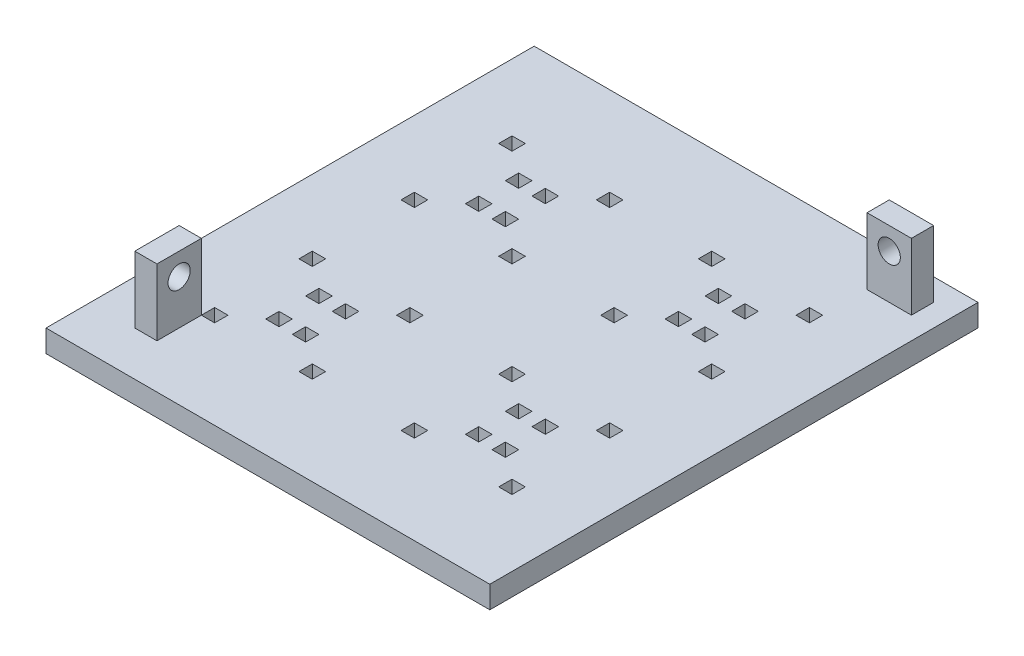
from build123d import *

# Parameters (mm, degrees)
SKETCH1_W           = 100
SKETCH1_H           = 110
SKETCH1_W_2         = 3
SKETCH1_H_2         = 3
BOSS_EXTRUDE1_DEPTH = 5
SKETCH2_W           = 10
SKETCH2_H           = 5
SKETCH2_W_2         = 5
SKETCH2_H_2         = 10
BOSS_EXTRUDE2_DEPTH = 15
SKETCH3_R           = 2.5
CUT_EXTRUDE1_DEPTH  = 15
SKETCH5_R           = 2.5
CUT_EXTRUDE2_DEPTH  = 15


with BuildPart() as part:
    # Sketch1 → Boss-Extrude1 (new body)
    with BuildSketch(Plane(origin=(0, 0, 0), x_dir=(1, 0, 0), z_dir=(0, 1, 0))):
        with Locations((-50, 55)):
            Rectangle(SKETCH1_W, SKETCH1_H)
        with Locations((-38.5, 43.5)):
            Rectangle(SKETCH1_W_2, SKETCH1_H_2, mode=Mode.SUBTRACT)
        with Locations((-16.5, 43.5)):
            Rectangle(SKETCH1_W_2, SKETCH1_H_2, mode=Mode.SUBTRACT)
        with Locations((-38.5, 21.5)):
            Rectangle(SKETCH1_W_2, SKETCH1_H_2, mode=Mode.SUBTRACT)
        with Locations((-16.5, 21.5)):
            Rectangle(SKETCH1_W_2, SKETCH1_H_2, mode=Mode.SUBTRACT)
        with Locations((-30.5, 37)):
            Rectangle(SKETCH1_W_2, SKETCH1_H_2, mode=Mode.SUBTRACT)
        with Locations((-30.5, 28)):
            Rectangle(SKETCH1_W_2, SKETCH1_H_2, mode=Mode.SUBTRACT)
        with Locations((-24.5, 37)):
            Rectangle(SKETCH1_W_2, SKETCH1_H_2, mode=Mode.SUBTRACT)
        with Locations((-24.5, 28)):
            Rectangle(SKETCH1_W_2, SKETCH1_H_2, mode=Mode.SUBTRACT)
        with Locations((-75.5, 28)):
            Rectangle(SKETCH1_W_2, SKETCH1_H_2, mode=Mode.SUBTRACT)
        with Locations((-75.5, 37)):
            Rectangle(SKETCH1_W_2, SKETCH1_H_2, mode=Mode.SUBTRACT)
        with Locations((-69.5, 28)):
            Rectangle(SKETCH1_W_2, SKETCH1_H_2, mode=Mode.SUBTRACT)
        with Locations((-69.5, 37)):
            Rectangle(SKETCH1_W_2, SKETCH1_H_2, mode=Mode.SUBTRACT)
        with Locations((-83.5, 21.5)):
            Rectangle(SKETCH1_W_2, SKETCH1_H_2, mode=Mode.SUBTRACT)
        with Locations((-61.5, 21.5)):
            Rectangle(SKETCH1_W_2, SKETCH1_H_2, mode=Mode.SUBTRACT)
        with Locations((-83.5, 43.5)):
            Rectangle(SKETCH1_W_2, SKETCH1_H_2, mode=Mode.SUBTRACT)
        with Locations((-61.5, 43.5)):
            Rectangle(SKETCH1_W_2, SKETCH1_H_2, mode=Mode.SUBTRACT)
        with Locations((-61.5, 66.5)):
            Rectangle(SKETCH1_W_2, SKETCH1_H_2, mode=Mode.SUBTRACT)
        with Locations((-83.5, 66.5)):
            Rectangle(SKETCH1_W_2, SKETCH1_H_2, mode=Mode.SUBTRACT)
        with Locations((-61.5, 88.5)):
            Rectangle(SKETCH1_W_2, SKETCH1_H_2, mode=Mode.SUBTRACT)
        with Locations((-83.5, 88.5)):
            Rectangle(SKETCH1_W_2, SKETCH1_H_2, mode=Mode.SUBTRACT)
        with Locations((-69.5, 73)):
            Rectangle(SKETCH1_W_2, SKETCH1_H_2, mode=Mode.SUBTRACT)
        with Locations((-69.5, 82)):
            Rectangle(SKETCH1_W_2, SKETCH1_H_2, mode=Mode.SUBTRACT)
        with Locations((-75.5, 73)):
            Rectangle(SKETCH1_W_2, SKETCH1_H_2, mode=Mode.SUBTRACT)
        with Locations((-75.5, 82)):
            Rectangle(SKETCH1_W_2, SKETCH1_H_2, mode=Mode.SUBTRACT)
        with Locations((-24.5, 82)):
            Rectangle(SKETCH1_W_2, SKETCH1_H_2, mode=Mode.SUBTRACT)
        with Locations((-24.5, 73)):
            Rectangle(SKETCH1_W_2, SKETCH1_H_2, mode=Mode.SUBTRACT)
        with Locations((-30.5, 82)):
            Rectangle(SKETCH1_W_2, SKETCH1_H_2, mode=Mode.SUBTRACT)
        with Locations((-30.5, 73)):
            Rectangle(SKETCH1_W_2, SKETCH1_H_2, mode=Mode.SUBTRACT)
        with Locations((-16.5, 88.5)):
            Rectangle(SKETCH1_W_2, SKETCH1_H_2, mode=Mode.SUBTRACT)
        with Locations((-38.5, 88.5)):
            Rectangle(SKETCH1_W_2, SKETCH1_H_2, mode=Mode.SUBTRACT)
        with Locations((-16.5, 66.5)):
            Rectangle(SKETCH1_W_2, SKETCH1_H_2, mode=Mode.SUBTRACT)
        with Locations((-38.5, 66.5)):
            Rectangle(SKETCH1_W_2, SKETCH1_H_2, mode=Mode.SUBTRACT)
    extrude(amount=BOSS_EXTRUDE1_DEPTH)

    # Sketch2 → Boss-Extrude2 (add)
    with BuildSketch(Plane(origin=(0, 5, 0), x_dir=(1, 0, 0), z_dir=(0, 1, 0))):
        with Locations((-10, 102.5)):
            Rectangle(SKETCH2_W, SKETCH2_H)
        with Locations((-87.5, 15)):
            Rectangle(SKETCH2_W_2, SKETCH2_H_2)
    extrude(amount=BOSS_EXTRUDE2_DEPTH)

    # Sketch3 → Cut-Extrude1 (cut)
    with BuildSketch(Plane(origin=(0, 0, -105), x_dir=(-1, 0, 0), z_dir=(0, 0, -1))):
        with Locations((10, 15)):
            Circle(SKETCH3_R)
    extrude(amount=-CUT_EXTRUDE1_DEPTH, mode=Mode.SUBTRACT)

    # Sketch5 → Cut-Extrude2 (cut)
    with BuildSketch(Plane.ZY.offset(90)):
        with Locations((-15, 15)):
            Circle(SKETCH5_R)
    extrude(amount=-CUT_EXTRUDE2_DEPTH, mode=Mode.SUBTRACT)


solid = part.part
